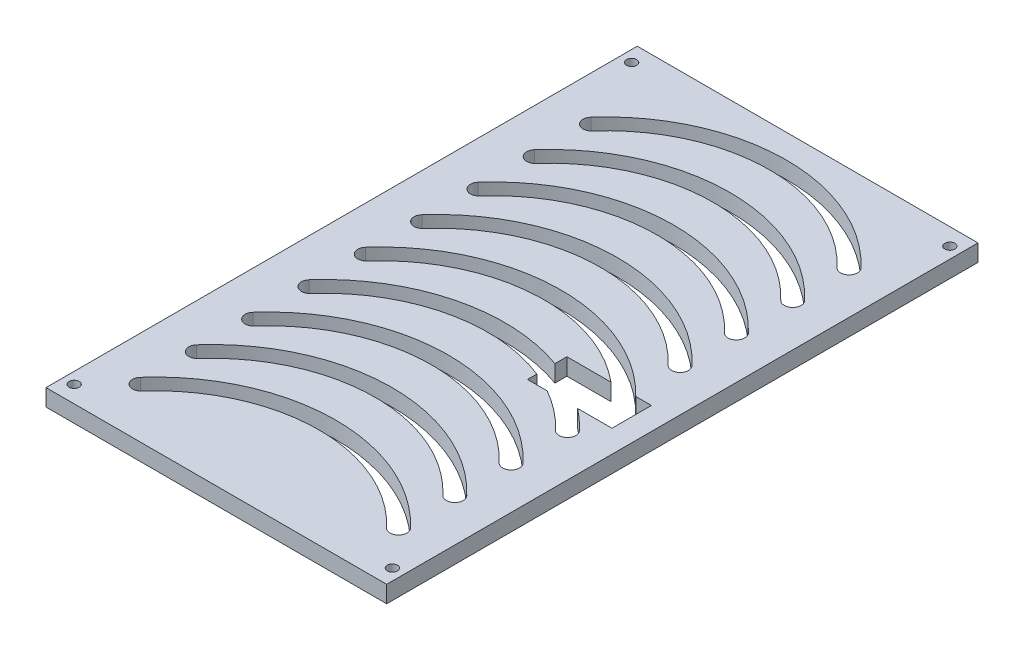
from build123d import *

# Parameters (mm, degrees)
SKETCH1_W           = 60.5
SKETCH1_H           = 105
BOSS_EXTRUDE1_DEPTH = 3
SKETCH2_R           = 0.9
CUT_EXTRUDE1_DEPTH  = 3
SKETCH4_R           = 0.9
CUT_EXTRUDE2_DEPTH  = 3
SKETCH5_W           = 15
SKETCH5_H           = 7
CUT_EXTRUDE3_DEPTH  = 3
CUT_EXTRUDE4_DEPTH  = 3


with BuildPart() as part:
    # Sketch1 → Boss-Extrude1 (new body)
    with BuildSketch(Plane(origin=(0, 0, 0), x_dir=(1, 0, 0), z_dir=(0, 1, 0))):
        Rectangle(SKETCH1_W, SKETCH1_H)
    extrude(amount=BOSS_EXTRUDE1_DEPTH)

    # Sketch2 → Cut-Extrude1 (cut)
    with BuildSketch(Plane(origin=(0, 3, 0), x_dir=(1, 0, 0), z_dir=(0, 1, 0))):
        with Locations((-28.25, 49.5)):
            Circle(SKETCH2_R)
        with Locations((28.25, 49.5)):
            Circle(SKETCH2_R)
    extrude(amount=-CUT_EXTRUDE1_DEPTH, mode=Mode.SUBTRACT)

    # Sketch4 → Cut-Extrude2 (cut)
    with BuildSketch(Plane(origin=(0, 3, 0), x_dir=(1, 0, 0), z_dir=(0, 1, 0))):
        with Locations((-28.25, -49.5)):
            Circle(SKETCH4_R)
        with Locations((28.25, -49.5)):
            Circle(SKETCH4_R)
    extrude(amount=-CUT_EXTRUDE2_DEPTH, mode=Mode.SUBTRACT)

    # Sketch5 → Cut-Extrude3 (cut)
    with BuildSketch(Plane(origin=(0, 3, 0), x_dir=(1, 0, 0), z_dir=(0, 1, 0))):
        with Locations((18.75, -5)):
            Rectangle(SKETCH5_W, SKETCH5_H)
    extrude(amount=-CUT_EXTRUDE3_DEPTH, mode=Mode.SUBTRACT)

    # Sketch6 → Cut-Extrude4 (cut)
    with BuildSketch(Plane(origin=(0, 3, 0), x_dir=(1, 0, 0), z_dir=(0, 1, 0))):
        with BuildLine():
            ThreePointArc((23.75286773, 38.214829885), (-0.024201003, 48.23018139), (-23.465757765, 37.452905298))
            ThreePointArc((-23.465757765, 37.452905298), (-23.337849069, 35.335444704), (-21.220388476, 35.4633534))
            ThreePointArc((-21.220388476, 35.4633534), (0.024201003, 45.230571874), (21.572857921, 36.153869615))
            ThreePointArc((21.572857921, 36.153869615), (23.693342961, 36.094344845), (23.75286773, 38.214829885))
        make_face()
        with BuildLine():
            ThreePointArc((23.75286773, 28.214829885), (-0.024201003, 38.23018139), (-23.465757765, 27.452905298))
            ThreePointArc((-23.465757765, 27.452905298), (-23.337849069, 25.335444704), (-21.220388476, 25.4633534))
            ThreePointArc((-21.220388476, 25.4633534), (0.024201003, 35.230571874), (21.572857921, 26.153869615))
            ThreePointArc((21.572857921, 26.153869615), (23.693342961, 26.094344845), (23.75286773, 28.214829885))
        make_face()
        with BuildLine():
            ThreePointArc((23.75286773, 18.214829885), (-0.024201003, 28.23018139), (-23.465757765, 17.452905298))
            ThreePointArc((-23.465757765, 17.452905298), (-23.337849069, 15.335444704), (-21.220388476, 15.4633534))
            ThreePointArc((-21.220388476, 15.4633534), (0.024201003, 25.230571874), (21.572857921, 16.153869615))
            ThreePointArc((21.572857921, 16.153869615), (23.693342961, 16.094344845), (23.75286773, 18.214829885))
        make_face()
        with BuildLine():
            ThreePointArc((23.75286773, 8.214829885), (-0.024201003, 18.23018139), (-23.465757765, 7.452905298))
            ThreePointArc((-23.465757765, 7.452905298), (-23.337849069, 5.335444704), (-21.220388476, 5.4633534))
            ThreePointArc((-21.220388476, 5.4633534), (0.024201003, 15.230571874), (21.572857921, 6.153869615))
            ThreePointArc((21.572857921, 6.153869615), (23.693342961, 6.094344845), (23.75286773, 8.214829885))
        make_face()
        with BuildLine():
            ThreePointArc((23.75286773, -1.785170115), (-0.024201003, 8.23018139), (-23.465757765, -2.547094702))
            ThreePointArc((-23.465757765, -2.547094702), (-23.337849069, -4.664555296), (-21.220388476, -4.5366466))
            ThreePointArc((-21.220388476, -4.5366466), (0.024201003, 5.230571874), (21.572857921, -3.846130385))
            ThreePointArc((21.572857921, -3.846130385), (23.693342961, -3.905655155), (23.75286773, -1.785170115))
        make_face()
        with BuildLine():
            ThreePointArc((23.75286773, -11.785170115), (-0.024201003, -1.76981861), (-23.465757765, -12.547094702))
            ThreePointArc((-23.465757765, -12.547094702), (-23.337849069, -14.664555296), (-21.220388476, -14.5366466))
            ThreePointArc((-21.220388476, -14.5366466), (0.024201003, -4.769428126), (21.572857921, -13.846130385))
            ThreePointArc((21.572857921, -13.846130385), (23.693342961, -13.905655155), (23.75286773, -11.785170115))
        make_face()
        with BuildLine():
            ThreePointArc((23.75286773, -21.785170115), (-0.024201003, -11.76981861), (-23.465757765, -22.547094702))
            ThreePointArc((-23.465757765, -22.547094702), (-23.337849069, -24.664555296), (-21.220388476, -24.5366466))
            ThreePointArc((-21.220388476, -24.5366466), (0.024201003, -14.769428126), (21.572857921, -23.846130385))
            ThreePointArc((21.572857921, -23.846130385), (23.693342961, -23.905655155), (23.75286773, -21.785170115))
        make_face()
        with BuildLine():
            ThreePointArc((23.75286773, -31.785170115), (-0.024201003, -21.76981861), (-23.465757765, -32.547094702))
            ThreePointArc((-23.465757765, -32.547094702), (-23.337849069, -34.664555296), (-21.220388476, -34.5366466))
            ThreePointArc((-21.220388476, -34.5366466), (0.024201003, -24.769428126), (21.572857921, -33.846130385))
            ThreePointArc((21.572857921, -33.846130385), (23.693342961, -33.905655155), (23.75286773, -31.785170115))
        make_face()
        with BuildLine():
            ThreePointArc((23.75286773, -41.785170115), (-0.024201003, -31.76981861), (-23.465757765, -42.547094702))
            ThreePointArc((-23.465757765, -42.547094702), (-23.337849069, -44.664555296), (-21.220388476, -44.5366466))
            ThreePointArc((-21.220388476, -44.5366466), (0.024201003, -34.769428126), (21.572857921, -43.846130385))
            ThreePointArc((21.572857921, -43.846130385), (23.693342961, -43.905655155), (23.75286773, -41.785170115))
        make_face()
    extrude(amount=-CUT_EXTRUDE4_DEPTH, mode=Mode.SUBTRACT)


solid = part.part
